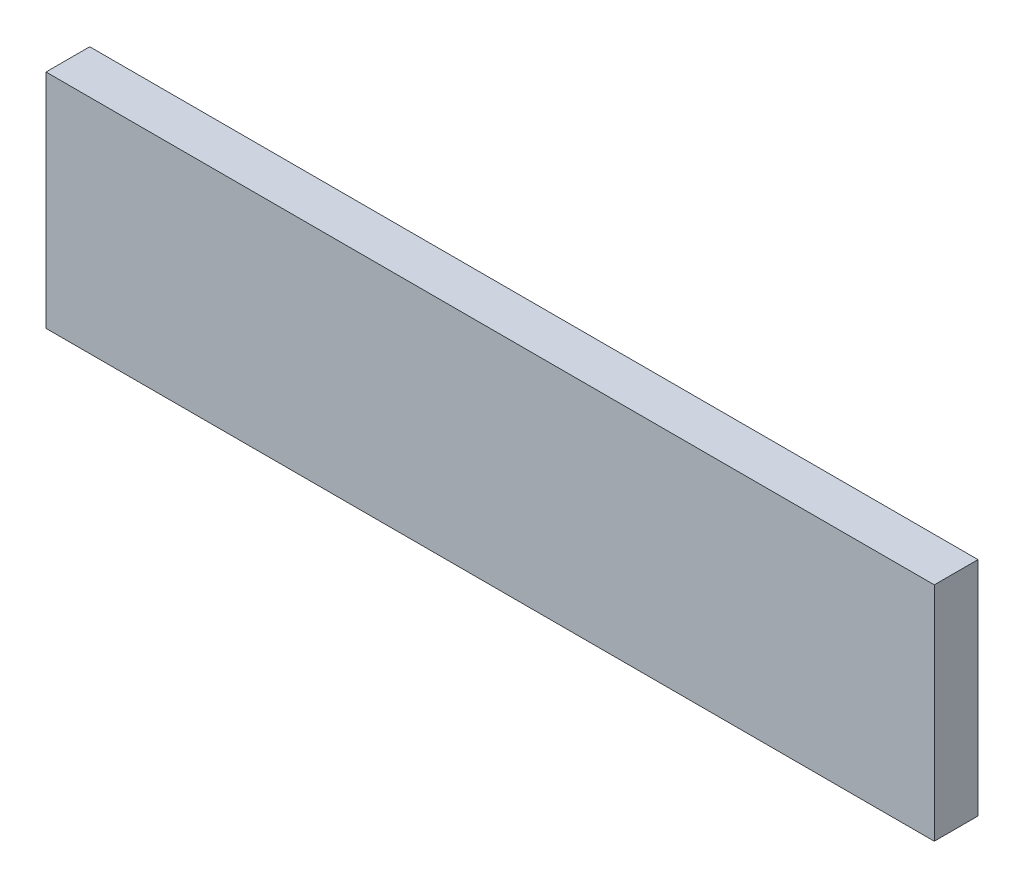
from build123d import *

# Parameters (mm, degrees)
SKETCH1_W           = 101.6
SKETCH1_H           = 25.4
BOSS_EXTRUDE1_DEPTH = 5


with BuildPart() as part:
    # Sketch1 → Boss-Extrude1 (new body)
    with BuildSketch(Plane.XY):
        with Locations((-21.675854902, 22.192494964)):
            Rectangle(SKETCH1_W, SKETCH1_H)
    extrude(amount=BOSS_EXTRUDE1_DEPTH)


solid = part.part
